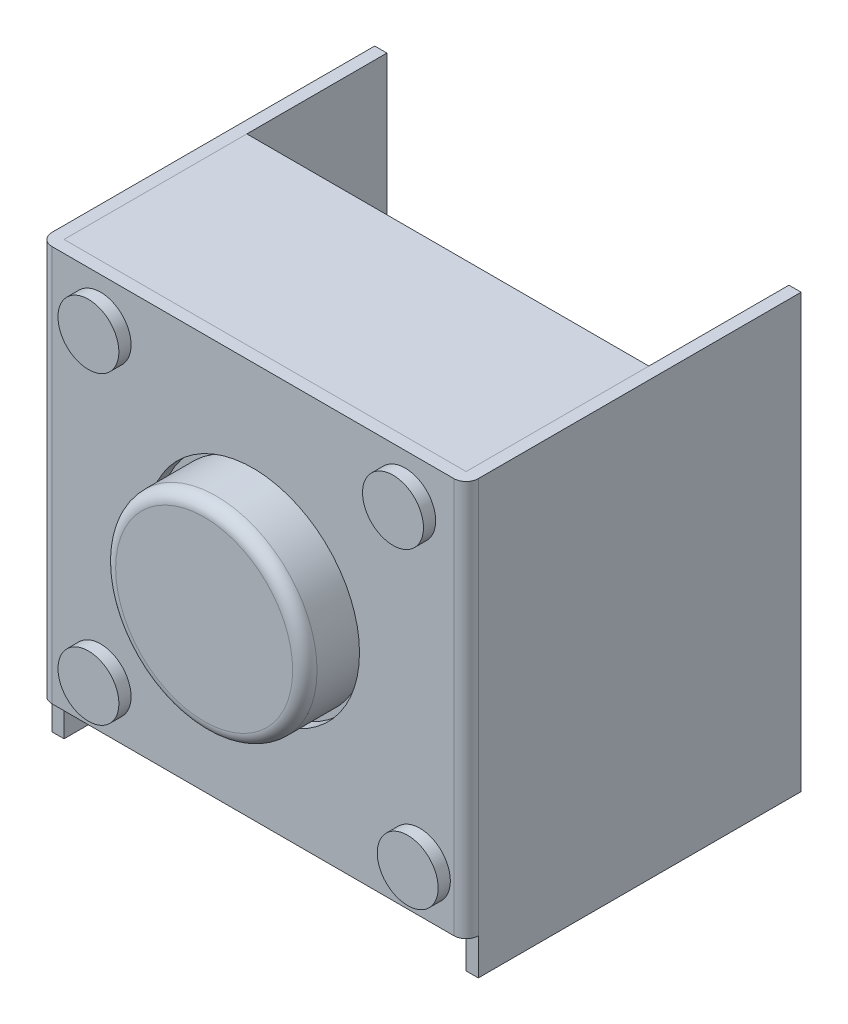
from build123d import *

# Parameters (mm, degrees)
CROQUIS1_W       = 7
CROQUIS1_H       = 6.5
CROQUIS1_R       = 1.75
CROQUIS1_R_2     = 0.5
EXTRUIR1_DEPTH   = 0.2
EXTRUIR2_DEPTH   = 0.2
REDONDEO1_R      = 0.2
CROQUIS3_W       = 6.6
CROQUIS3_H       = 6.5
EXTRUIR3_DEPTH   = 3
CROQUIS4_R       = 1.652823383
EXTRUIR5_DEPTH   = 1
CROQUIS5_R       = 0.5
EXTRUIR6_DEPTH   = 0.4
EXTRUIR6_2_DEPTH = 0.4
EXTRUIR6_3_DEPTH = 0.4
EXTRUIR6_4_DEPTH = 0.4
REDONDEO2_R      = 0.2


with BuildPart() as part:
    # Croquis1 → Extruir1 (new body)
    with BuildSketch(Plane.XY):
        Rectangle(CROQUIS1_W, CROQUIS1_H)
        Circle(CROQUIS1_R, mode=Mode.SUBTRACT)
        with Locations((2.5, 2.5)):
            Circle(CROQUIS1_R_2, mode=Mode.SUBTRACT)
        with Locations((2.741434569, -2.5)):
            Circle(CROQUIS1_R_2, mode=Mode.SUBTRACT)
        with Locations((-2.5, -2.5)):
            Circle(CROQUIS1_R_2, mode=Mode.SUBTRACT)
        with Locations((-2.5, 2.5)):
            Circle(CROQUIS1_R_2, mode=Mode.SUBTRACT)
    extrude(amount=EXTRUIR1_DEPTH)

    # Croquis2 → Extruir2 (add)
    with BuildSketch(Plane(origin=(3.5, 0, 0), x_dir=(0, 0, -1), z_dir=(1, 0, 0))):
        Polygon((-0.2, 3.25), (5.3, 3.25), (5.3, -3.85), (0, -3.85), (0, -3.25), (-0.2, -3.25), align=None)
    extruir2 = extrude(amount=-EXTRUIR2_DEPTH)

    # Simetría1: Extruir2 across plane
    add(extruir2.mirror(Plane(origin=(0, 0, 0), x_dir=(0, 0, 1), z_dir=(1, 0, 0))))

    # Redondeo1
    redondeo1_edges = [part.edges().sort_by_distance(p)[0] for p in [
        (-3.5, 0, 0.2),
        (3.5, 0, 0.2),
    ]]
    fillet(redondeo1_edges, radius=REDONDEO1_R)


with BuildPart() as body_2:
    # Croquis3 → Extruir3 (new body)
    with BuildSketch(Plane(origin=(0, 0, 0), x_dir=(-1, 0, 0), z_dir=(0, 0, -1))):
        Rectangle(CROQUIS3_W, CROQUIS3_H)
    extrude(amount=EXTRUIR3_DEPTH)


with BuildPart() as body_3:
    # Croquis4 → Extruir5 (new body)
    with BuildSketch(Plane.XY):
        Circle(CROQUIS4_R)
    extrude(amount=EXTRUIR5_DEPTH)

    # Redondeo2
    redondeo2_edges = [body_3.edges().sort_by_distance(p)[0] for p in [
        (-1.652823383, 0, 1),
    ]]
    fillet(redondeo2_edges, radius=REDONDEO2_R)


with BuildPart() as body_4:
    # Croquis5 → Extruir6 (new body)
    with BuildSketch(Plane.XY):
        with Locations((2.5, 2.5)):
            Circle(CROQUIS5_R)
    extrude(amount=EXTRUIR6_DEPTH)


with BuildPart() as body_5:
    # Croquis5 → Extruir6 2 (new body)
    with BuildSketch(Plane.XY):
        with Locations((-2.5, 2.5)):
            Circle(CROQUIS5_R)
    extrude(amount=EXTRUIR6_2_DEPTH)


with BuildPart() as body_6:
    # Croquis5 → Extruir6 3 (new body)
    with BuildSketch(Plane.XY):
        with Locations((-2.5, -2.5)):
            Circle(CROQUIS5_R)
    extrude(amount=EXTRUIR6_3_DEPTH)


with BuildPart() as body_7:
    # Croquis5 → Extruir6 4 (new body)
    with BuildSketch(Plane.XY):
        with Locations((2.741434569, -2.5)):
            Circle(CROQUIS5_R)
    extrude(amount=EXTRUIR6_4_DEPTH)


solid = Compound([part.part, body_2.part, body_3.part, body_4.part, body_5.part, body_6.part, body_7.part])
